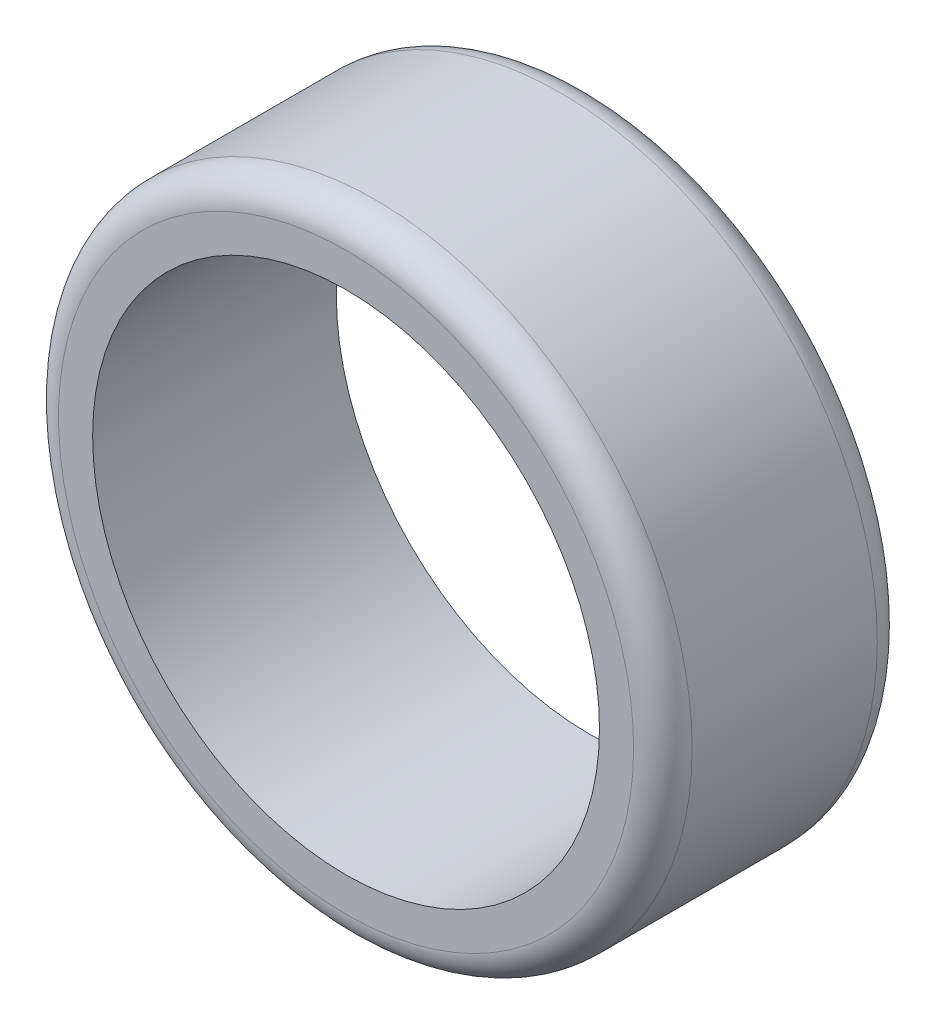
from build123d import *

# Parameters (mm, degrees)
SKETCH1_R           = 32.5
SKETCH1_R_2         = 26
BOSS_EXTRUDE1_DEPTH = 12.5
FILLET1_R           = 3


with BuildPart() as part:
    # Sketch1 → Boss-Extrude1 (new body, symmetric)
    with BuildSketch(Plane.XY):
        Circle(SKETCH1_R)
        Circle(SKETCH1_R_2, mode=Mode.SUBTRACT)
    extrude(amount=BOSS_EXTRUDE1_DEPTH, both=True)

    # Fillet1
    fillet1_edges = [part.edges().sort_by_distance(p)[0] for p in [
        (-32.5, 0, -12.5),
        (-32.5, 0, 12.5),
    ]]
    fillet(fillet1_edges, radius=FILLET1_R)


solid = part.part
